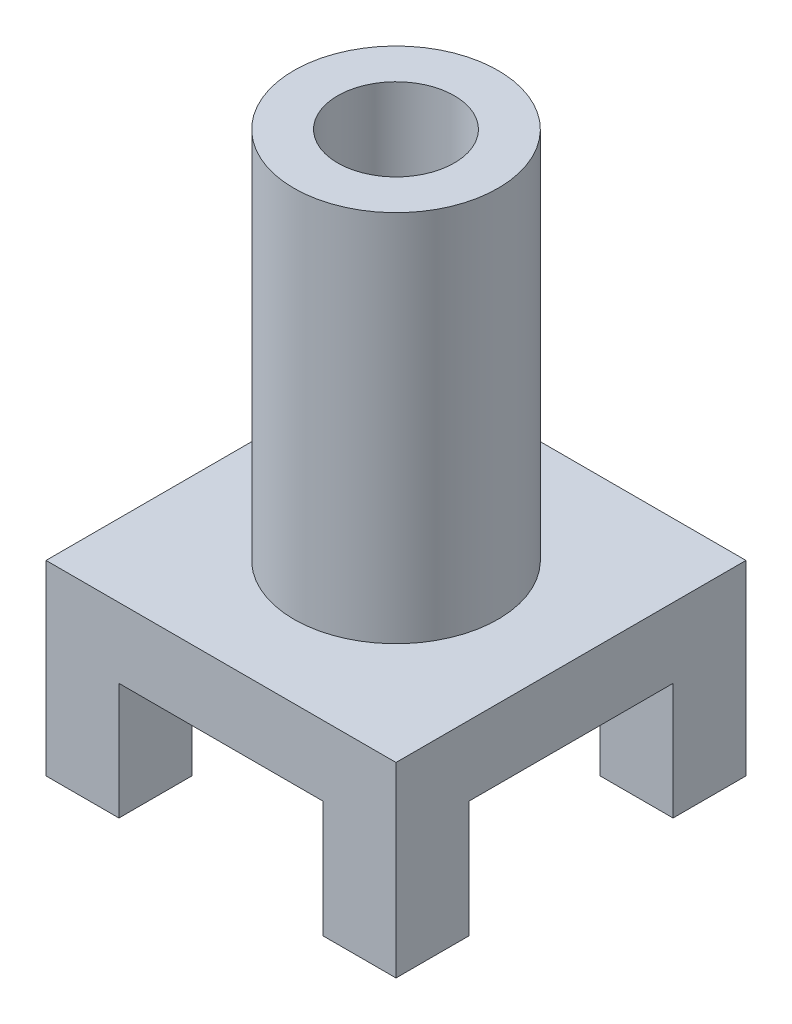
from build123d import *

# Parameters (mm, degrees)
SKETCH2_W               = 60
SKETCH2_H               = 60
BOSS_EXTRUDE2_DEPTH     = 32
SKETCH3_W               = 35
SKETCH3_H               = 20
CUT_EXTRUDE1_DEPTH      = 60
SKETCH4_W               = 35
SKETCH4_H               = 20
CUT_EXTRUDE2_DEPTH      = 61
SKETCH5_R               = 17.5
BOSS_EXTRUDE3_DEPTH     = 64
SKETCH6_R               = 10
CUT_EXTRUDE3_DEPTH      = 1
CUT_EXTRUDE3_DEPTH_BACK = 97


with BuildPart() as part:
    # Sketch2 → Boss-Extrude2 (new body)
    with BuildSketch(Plane(origin=(0, 0, 0), x_dir=(1, 0, 0), z_dir=(0, 1, 0))):
        Rectangle(SKETCH2_W, SKETCH2_H)
    extrude(amount=BOSS_EXTRUDE2_DEPTH)

    # Sketch3 → Cut-Extrude1 (cut)
    with BuildSketch(Plane.XY.offset(30)):
        with Locations((0, 10)):
            Rectangle(SKETCH3_W, SKETCH3_H)
    extrude(amount=-CUT_EXTRUDE1_DEPTH, mode=Mode.SUBTRACT)

    # Sketch4 → Cut-Extrude2 (cut, through all)
    with BuildSketch(Plane(origin=(30, 0, 0), x_dir=(0, 0, -1), z_dir=(1, 0, 0))):
        with Locations((0, 10)):
            Rectangle(SKETCH4_W, SKETCH4_H)
    extrude(amount=-CUT_EXTRUDE2_DEPTH, mode=Mode.SUBTRACT)

    # Sketch5 → Boss-Extrude3 (add)
    with BuildSketch(Plane(origin=(0, 32, 0), x_dir=(1, 0, 0), z_dir=(0, 1, 0))):
        Circle(SKETCH5_R)
    extrude(amount=BOSS_EXTRUDE3_DEPTH)

    # Sketch6 → Cut-Extrude3 (cut, two sides)
    with BuildSketch(Plane(origin=(0, 96, 0), x_dir=(1, 0, 0), z_dir=(0, 1, 0))) as cut_extrude3_sk:
        Circle(SKETCH6_R)
    extrude(amount=CUT_EXTRUDE3_DEPTH, mode=Mode.SUBTRACT)
    extrude(cut_extrude3_sk.sketch, amount=-CUT_EXTRUDE3_DEPTH_BACK, mode=Mode.SUBTRACT)


solid = part.part
